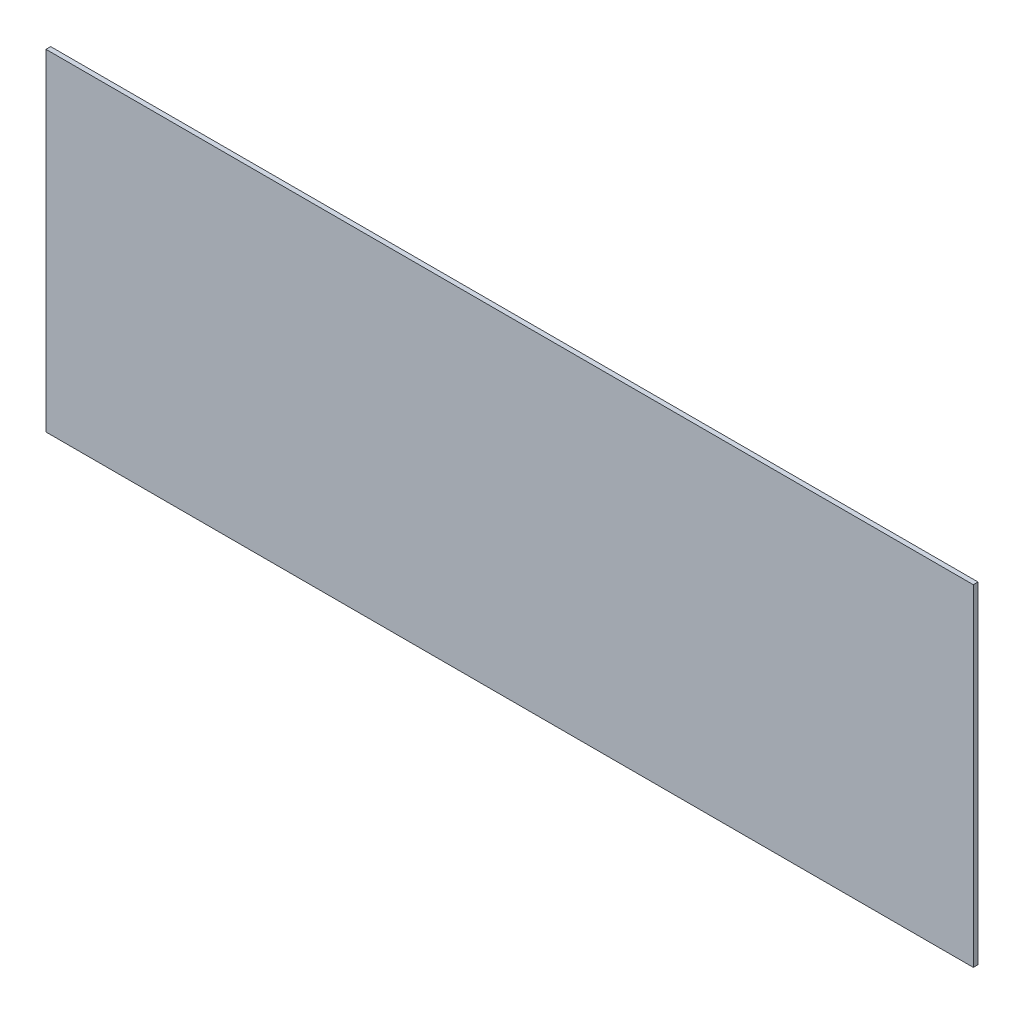
from build123d import *

# Parameters (mm, degrees)
CROQUIS1_W              = 196.4
CROQUIS1_H              = 70.2
SALIENTE_EXTRUIR1_DEPTH = 1


with BuildPart() as part:
    # Croquis1 → Saliente-Extruir1 (new body)
    with BuildSketch(Plane.XY):
        Rectangle(CROQUIS1_W, CROQUIS1_H)
    extrude(amount=SALIENTE_EXTRUIR1_DEPTH)


solid = part.part
